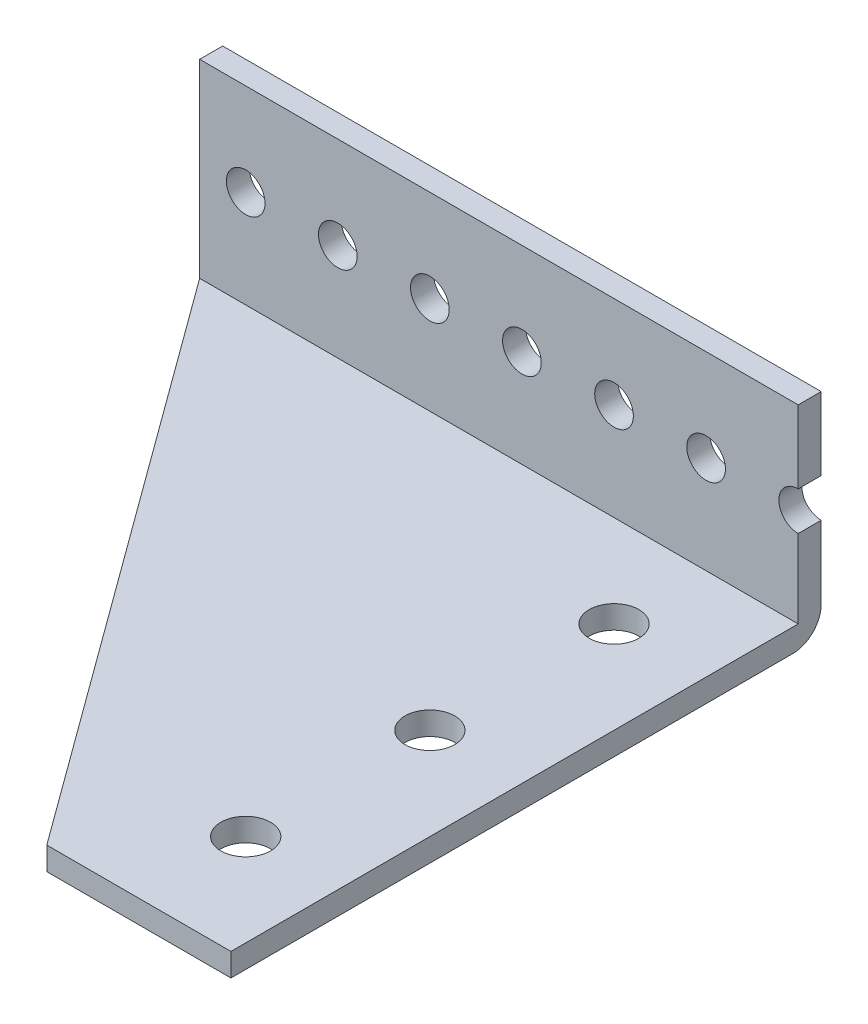
from build123d import *

# Parameters (mm, degrees)
BOSS_EXTRUDE1_START    = -34.925
SKETCH1_W              = 82.55
SKETCH1_H              = 81.407
BOSS_EXTRUDE1_DEPTH    = 3.175
SKETCH3_W              = 82.55
SKETCH3_H              = 3.175
BOSS_EXTRUDE2_DEPTH    = 50.8
F_10_CLEARANCE_HOLE2_D = 5.334
CHAMFER1_SIZE          = 3.175
FILLET2_R              = 3.937
SKETCH9_R              = 3.429
CUT_EXTRUDE2_DEPTH     = 54.975
SKETCH10_W             = 82.55
SKETCH10_H             = 24.638
CUT_EXTRUDE3_DEPTH     = 82.407


with BuildPart() as part:
    # Sketch1 → Boss-Extrude1 (new body)
    with BuildSketch(Plane(origin=(0, 0, 0), x_dir=(1, 0, 0), z_dir=(0, 1, 0)).offset(BOSS_EXTRUDE1_START)):
        Rectangle(SKETCH1_W, SKETCH1_H)
    extrude(amount=BOSS_EXTRUDE1_DEPTH)

    # Sketch3 → Boss-Extrude2 (add)
    with BuildSketch(Plane(origin=(0, -31.75, 0), x_dir=(1, 0, 0), z_dir=(0, 1, 0))):
        with Locations((0, 39.116)):
            Rectangle(SKETCH3_W, SKETCH3_H)
    extrude(amount=BOSS_EXTRUDE2_DEPTH)

    # #10 Clearance Hole2 (through all)
    with Locations(Plane(origin=(0, 0, -40.7035), x_dir=(-1, 0, 0), z_dir=(0, 0, -1))):
        with Locations((22.225, 7.112), (9.525, 7.112), (-3.175, 7.112), (-15.875, 7.112), (-28.575, 7.112), (22.225, -18.288), (9.525, -18.288), (-3.175, -18.288), (-15.875, -18.288), (-28.575, -18.288), (34.925, 7.112), (34.925, -18.288), (-41.275, 7.112), (-41.275, -18.288)):
            Hole(F_10_CLEARANCE_HOLE2_D / 2)

    # Chamfer1
    chamfer1_edges = [part.edges().sort_by_distance(p)[0] for p in [
        (-41.275, 19.05, -39.116),
    ]]
    chamfer(chamfer1_edges, length=CHAMFER1_SIZE)

    # Fillet2
    fillet2_edges = [part.edges().sort_by_distance(p)[0] for p in [
        (0, -34.925, -40.7035),
    ]]
    fillet(fillet2_edges, radius=FILLET2_R)

    # Sketch9 → Cut-Extrude2 (cut, through all)
    with BuildSketch(Plane.XZ.offset(34.925)):
        with Locations((28.575, -24.8285)):
            Circle(SKETCH9_R)
        with Locations((28.575, 0.5715)):
            Circle(SKETCH9_R)
        with Locations((28.575, 25.9715)):
            Circle(SKETCH9_R)
        Polygon((-41.275, -37.5285), (-41.275, 40.7035), (15.875, 40.7035), align=None)
    extrude(amount=-CUT_EXTRUDE2_DEPTH, mode=Mode.SUBTRACT)

    # Sketch10 → Cut-Extrude3 (cut, through all)
    with BuildSketch(Plane(origin=(0, 0, -40.7035), x_dir=(-1, 0, 0), z_dir=(0, 0, -1))):
        with Locations((0, 6.731)):
            Rectangle(SKETCH10_W, SKETCH10_H)
    extrude(amount=-CUT_EXTRUDE3_DEPTH, mode=Mode.SUBTRACT)


solid = part.part
